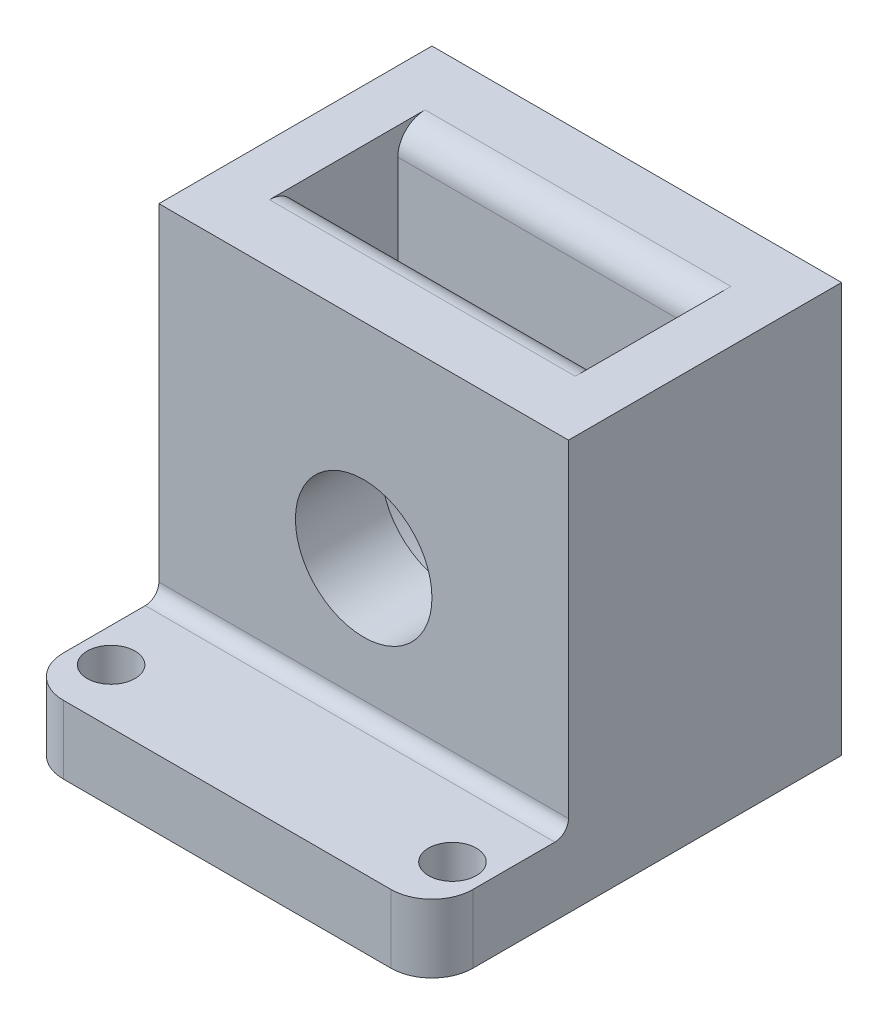
from build123d import *

# Parameters (mm, degrees)
SKETCH2_W           = 30
SKETCH2_H           = 30
SKETCH2_R           = 5
BOSS_EXTRUDE1_DEPTH = 20
CUT_EXTRUDE2_START  = 10
CUT_EXTRUDE2_DEPTH  = 3.7
SKETCH4_W           = 30
SKETCH4_H           = 10
SKETCH4_R           = 1.75
BOSS_EXTRUDE2_DEPTH = 5
FILLET2_R           = 3
FILLET3_R           = 1
FILLET4_R           = 2


with BuildPart() as part:
    # Sketch2 → Boss-Extrude1 (new body)
    with BuildSketch(Plane.XY):
        Rectangle(SKETCH2_W, SKETCH2_H)
        Circle(SKETCH2_R, mode=Mode.SUBTRACT)
    extrude(amount=BOSS_EXTRUDE1_DEPTH)

    # Sketch3 → Cut-Extrude2 (cut, symmetric)
    with BuildSketch(Plane.XY.offset(CUT_EXTRUDE2_START)):
        with BuildLine():
            Line((-11.2, 15), (-11.2, 0))
            ThreePointArc((-11.2, 0), (0, -11.2), (11.2, 0))
            Line((11.2, 0), (11.2, 15))
            Line((11.2, 15), (-11.2, 15))
        make_face()
    extrude(amount=CUT_EXTRUDE2_DEPTH, both=True, mode=Mode.SUBTRACT)

    # Sketch4 → Boss-Extrude2 (add)
    with BuildSketch(Plane.XZ.offset(15)):
        with Locations((0, 25)):
            Rectangle(SKETCH4_W, SKETCH4_H)
        with Locations((-12.5, 26)):
            Circle(SKETCH4_R, mode=Mode.SUBTRACT)
        with Locations((12.5, 26)):
            Circle(SKETCH4_R, mode=Mode.SUBTRACT)
    extrude(amount=-BOSS_EXTRUDE2_DEPTH)

    # Fillet2
    fillet2_edges = [part.edges().sort_by_distance(p)[0] for p in [
        (-15, -12.5, 30),
        (15, -12.5, 30),
    ]]
    fillet(fillet2_edges, radius=FILLET2_R)

    # Fillet3
    fillet3_edges = [part.edges().sort_by_distance(p)[0] for p in [
        (0, -10, 20),
    ]]
    fillet(fillet3_edges, radius=FILLET3_R)

    # Fillet4
    fillet4_edges = [part.edges().sort_by_distance(p)[0] for p in [
        (0, 15, 6.3),
        (0, 15, 13.7),
    ]]
    fillet(fillet4_edges, radius=FILLET4_R)


solid = part.part
